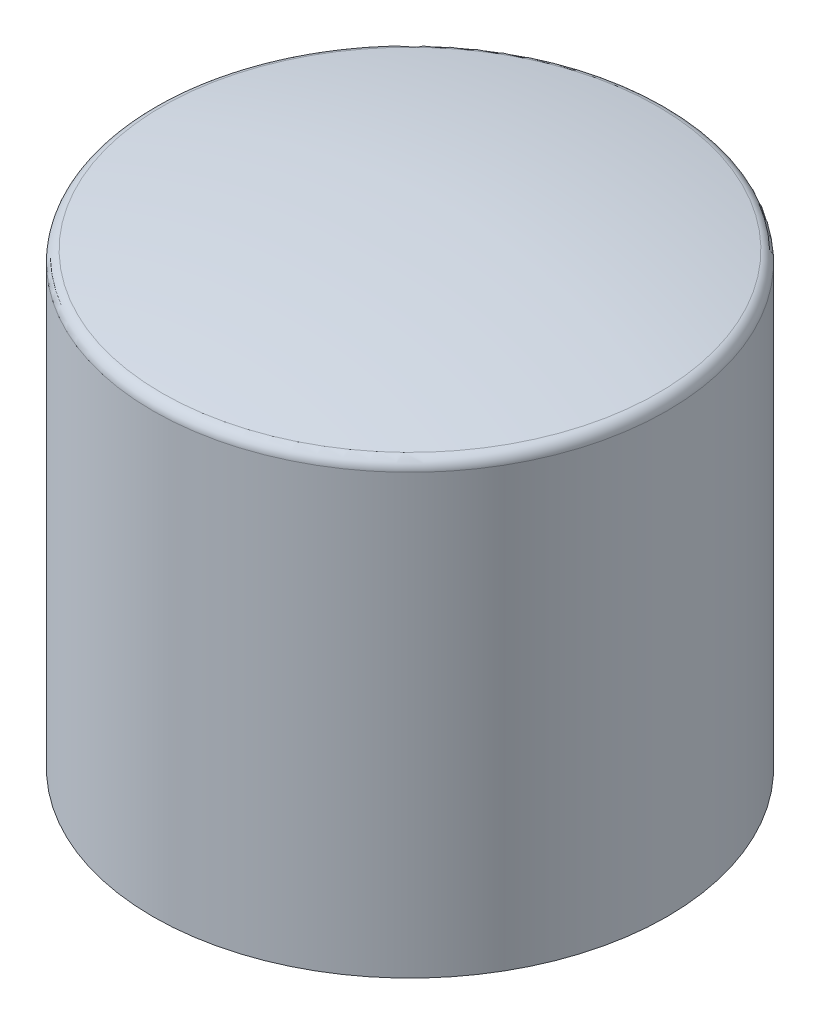
from build123d import *

# Parameters (mm, degrees)
FILLET1_R = 0.5


with BuildPart() as part:
    # Sketch2 → Revolve1 (revolve)
    with BuildSketch(Plane(origin=(0, 0, 0), x_dir=(0, 0, -1), z_dir=(1, 0, 0))):
        with BuildLine():
            Line((11.5, -1.169799841), (11.5, -21.169799841))
            Line((11.5, -21.169799841), (0, -21.169799841))
            Line((0, -21.169799841), (0, 0))
            add(Edge.make_bspline(
                [(0, 0), (5.809154566, 0.024080352), (11.5, -1.169799841)],
                knots=[0, 0, 0, 1, 1, 1], degree=2))
        make_face()
    revolve(axis=Axis((0, -21.169799841, 0), (0, 1, 0)))

    # Fillet1
    fillet1_edges = [part.edges().sort_by_distance(p)[0] for p in [
        (0, -1.169799841, 11.5),
    ]]
    fillet(fillet1_edges, radius=FILLET1_R)


solid = part.part
